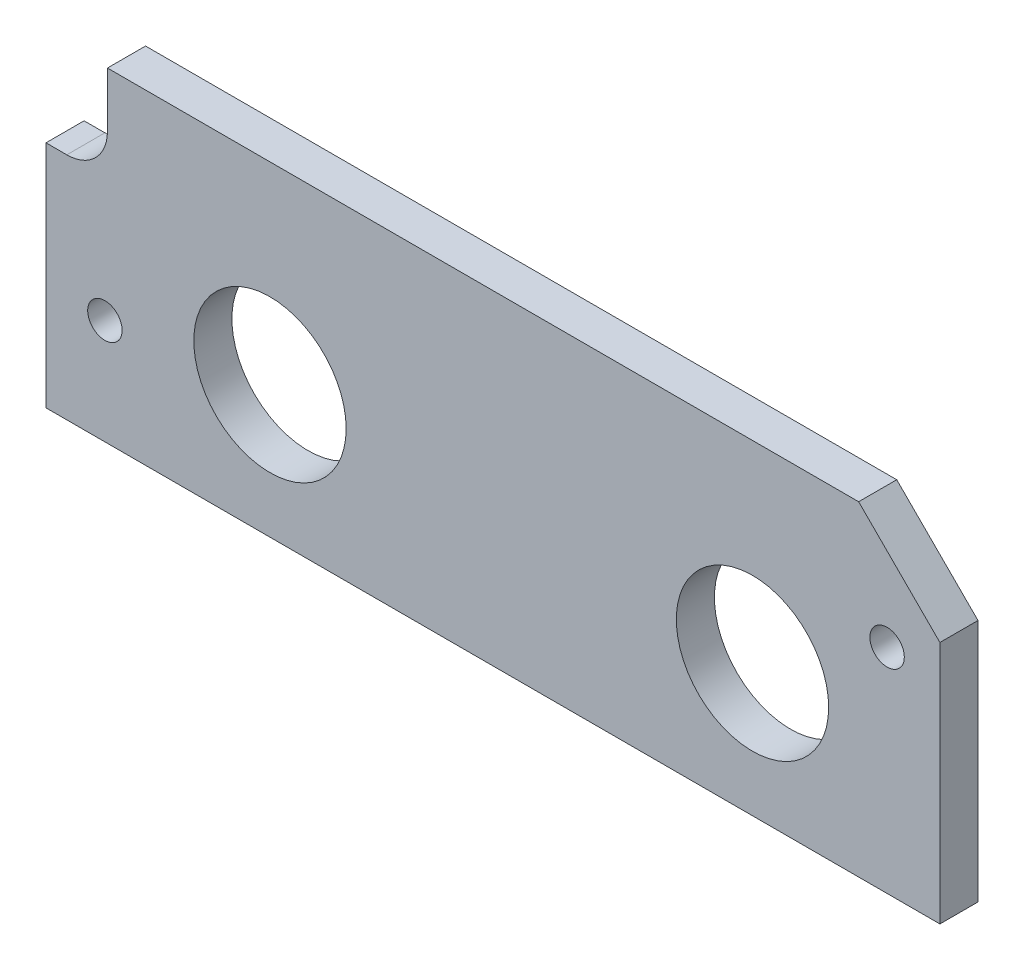
from build123d import *

# Parameters (mm, degrees)
BOSS_EXTRUDE1_DEPTH         = 4.7625
F_6_CLEARANCE_HOLE1_D       = 4.3053
F_3_4_0_75_DIAMETER_HOLE1_D = 19.05


with BuildPart() as part:
    # Sketch1 → Boss-Extrude1 (new body)
    with BuildSketch(Plane.XY):
        with BuildLine():
            Line((-133.0325, 57.658), (-133.0325, 50.8))
            ThreePointArc((-133.0325, 50.8), (-134.520397552, 47.207897552), (-138.1125, 45.72))
            Line((-138.1125, 45.72), (-140.716, 45.72))
            Line((-140.716, 45.72), (-140.716, 17.018))
            Line((-140.716, 17.018), (-28.956, 17.018))
            Line((-28.956, 17.018), (-28.956, 47.498))
            Line((-28.956, 47.498), (-39.116, 57.658))
            Line((-39.116, 57.658), (-133.0325, 57.658))
        make_face()
    extrude(amount=BOSS_EXTRUDE1_DEPTH)

    # #6 Clearance Hole1 (through all)
    with Locations(Plane.XY.offset(4.7625)):
        with Locations((-133.35, 30.1625), (-35.56, 43.688)):
            Hole(F_6_CLEARANCE_HOLE1_D / 2)

    # 3/4 (0.75) Diameter Hole1 (through all)
    with Locations(Plane.XY.offset(4.7625)):
        with Locations((-112.7125, 33.528), (-52.3875, 33.528)):
            Hole(F_3_4_0_75_DIAMETER_HOLE1_D / 2)


solid = part.part
